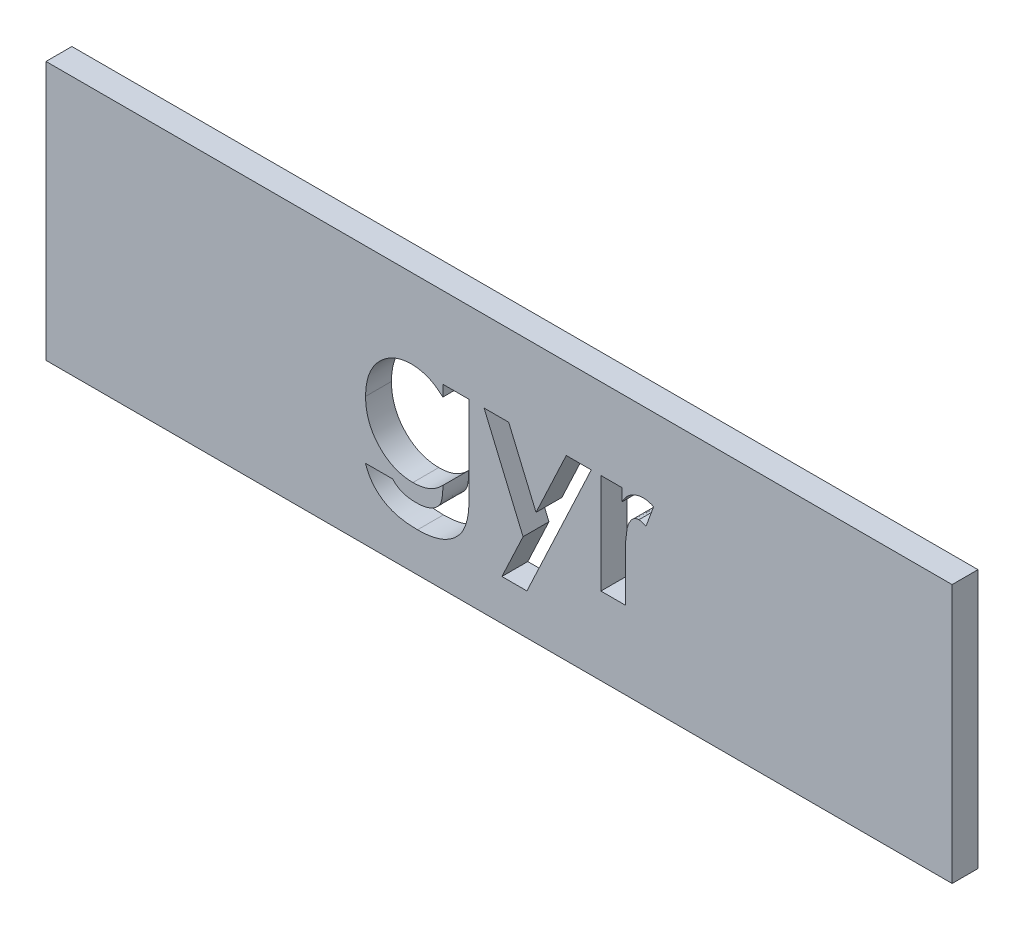
from build123d import *

# Parameters (mm, degrees)
ESQUISSE1_W             = 35
ESQUISSE1_H             = 10
BOSS_EXTRU_1_DEPTH      = 1
ESQUISSE2_R             = 1
BOSS_EXTRU_2_DEPTH      = 3
CHANFREIN1_SIZE         = 0.5
ENL_V_MAT_EXTRU_2_DEPTH = 1


with BuildPart() as part:
    # Esquisse1 → Boss.-Extru.1 (new body)
    with BuildSketch(Plane.XY):
        with Locations((17.5, -5)):
            Rectangle(ESQUISSE1_W, ESQUISSE1_H)
    extrude(amount=BOSS_EXTRU_1_DEPTH)

    # Esquisse2 → Boss.-Extru.2 (add)
    with BuildSketch(Plane(origin=(0, 0, 0), x_dir=(-1, 0, 0), z_dir=(0, 0, -1))):
        with Locations(Location((-30, -5, 0), (0, 0, 180))):  # turned: the seam where the file's is
            Circle(ESQUISSE2_R)
        with Locations(Location((-5, -5, 0), (0, 0, 180))):  # turned: the seam where the file's is
            Circle(ESQUISSE2_R)
    extrude(amount=BOSS_EXTRU_2_DEPTH)

    # Chanfrein1
    chanfrein1_edges = [part.edges().sort_by_distance(p)[0] for p in [
        (29, -5, -3),
        (4, -5, -3),
    ]]
    chamfer(chanfrein1_edges, length=CHANFREIN1_SIZE)

    # Esquisse3 → Enlèv. mat.-Extru.2 (cut)
    with BuildSketch(Plane.XY.offset(1)):
        with BuildLine():
            Line((15.329059829, -3.133012821), (16.346688034, -3.133012821))
            Line((16.346688034, -3.133012821), (16.346688034, -6.431824252))
            add(Edge.make_bspline(
                [(16.346688034, -6.431824252), (16.34546511, -6.510655339), (16.343103596, -6.662881264), (16.325089291, -6.883495949), (16.295048115, -7.088017896), (16.251819923, -7.276736757), (16.195988635, -7.4489589), (16.127704852, -7.605256879), (16.048356925, -7.746468877), (15.983115267, -7.828982437), (15.951297075, -7.869224092)],
                knots=[0, 0, 0, 0, 1.243822755, 2.401870584, 3.490053692, 4.503076575, 5.453444971, 6.342269266, 7.191528908, 8, 8, 8, 8], degree=3))
            add(Edge.make_bspline(
                [(15.951297075, -7.869224092), (15.905605713, -7.919342306), (15.814454312, -8.019324999), (15.653749283, -8.145499618), (15.477691005, -8.253338799), (15.284482771, -8.341718176), (15.074354715, -8.409035067), (14.847846635, -8.457515225), (14.604814931, -8.487710952), (14.436959436, -8.490887878), (14.350652711, -8.492521368)],
                knots=[0, 0, 0, 0, 0.916003385, 1.827369254, 2.751972866, 3.703651841, 4.69362366, 5.730423306, 6.83304546, 8, 8, 8, 8], degree=3))
            add(Edge.make_bspline(
                [(14.350652711, -8.492521368), (14.259421509, -8.491108999), (14.083960416, -8.488392649), (13.831826444, -8.461820527), (13.60215669, -8.418097933), (13.39387263, -8.356542717), (13.20503379, -8.277118686), (13.032079147, -8.181884691), (12.875340855, -8.068024611), (12.732449742, -7.940027217), (12.606719722, -7.795081621), (12.49935862, -7.6345149), (12.407892543, -7.459803946), (12.362730127, -7.334865629), (12.339776976, -7.271367521)],
                knots=[0, 0, 0, 0, 1.29412125, 2.488928388, 3.592140377, 4.607309753, 5.564519828, 6.493640275, 7.402258018, 8.307438948, 9.210158992, 10.116782752, 11.042881838, 12, 12, 12, 12], degree=3))
            Line((12.339776976, -7.271367521), (13.395566239, -7.271367521))
            add(Edge.make_bspline(
                [(13.395566239, -7.271367521), (13.419964401, -7.298227571), (13.469070776, -7.35228901), (13.555926573, -7.420889314), (13.65200877, -7.47960783), (13.758092556, -7.527688831), (13.874620253, -7.564250121), (14.000798638, -7.592026884), (14.137192891, -7.607680544), (14.231183716, -7.609591785), (14.279630743, -7.610576923)],
                knots=[0, 0, 0, 0, 0.888971165, 1.789239437, 2.70354581, 3.646217955, 4.638595249, 5.694475788, 6.811630907, 8, 8, 8, 8], degree=3))
            add(Edge.make_bspline(
                [(14.279630743, -7.610576923), (14.340855044, -7.609432982), (14.457788095, -7.607248154), (14.623222566, -7.583359441), (14.770958794, -7.5476711), (14.898864132, -7.493961019), (15.009214297, -7.42944782), (15.101273205, -7.354507352), (15.177287089, -7.271963013), (15.227008123, -7.194308957), (15.256554212, -7.123864138), (15.276673336, -7.06303605), (15.291952015, -6.992920639), (15.305859644, -6.914830211), (15.316255823, -6.827758701), (15.323143424, -6.73189057), (15.329116008, -6.627648194), (15.329078969, -6.555150823), (15.329059829, -6.517686632)],
                knots=[0, 0, 0, 0, 1.656375485, 3.163532, 4.516250129, 5.759907703, 6.905105653, 7.965920022, 8.961443813, 9.932912751, 10.442911961, 11.026787936, 11.664959534, 12.383728702, 13.174001396, 14.037595414, 14.985895623, 16, 16, 16, 16], degree=3))
            add(Edge.make_bspline(
                [(15.329059829, -6.517686632), (15.287449979, -6.55849698), (15.206252796, -6.638134021), (15.074441855, -6.739733739), (14.939510017, -6.823652606), (14.800681847, -6.89036443), (14.655196371, -6.939229664), (14.502199099, -6.974324949), (14.339947583, -6.995709064), (14.228461376, -6.99854913), (14.171507746, -7)],
                knots=[0, 0, 0, 0, 1.082007397, 2.111422008, 3.08419067, 4.02964304, 4.965866572, 5.929243163, 6.942137121, 8, 8, 8, 8], degree=3))
            add(Edge.make_bspline(
                [(14.171507746, -7), (14.108510402, -6.998544642), (13.984761279, -6.995685803), (13.802999283, -6.967903474), (13.628614811, -6.92467688), (13.461138298, -6.864501419), (13.302278657, -6.784609692), (13.149775257, -6.689560821), (13.006454432, -6.574363867), (12.870338898, -6.445449499), (12.747314548, -6.302155537), (12.639060729, -6.148258015), (12.547800043, -5.984818516), (12.473584153, -5.811988974), (12.414453061, -5.63049492), (12.373758282, -5.439353789), (12.348890609, -5.238888314), (12.345663197, -5.102267354), (12.344017094, -5.03258547)],
                knots=[0, 0, 0, 0, 1.007560175, 1.979205489, 2.935124557, 3.879618859, 4.820364716, 5.775815361, 6.749909327, 7.75781854, 8.772289371, 9.766897274, 10.764314289, 11.762244114, 12.772609037, 13.814079916, 14.885097635, 16, 16, 16, 16], degree=3))
            add(Edge.make_bspline(
                [(12.344017094, -5.03258547), (12.345454802, -4.958295142), (12.348264622, -4.813103955), (12.375808883, -4.601033686), (12.418669084, -4.399625491), (12.479853148, -4.209300672), (12.560235277, -4.030872859), (12.657373865, -3.863775883), (12.770352577, -3.706098926), (12.859784665, -3.612559125), (12.904772636, -3.565504808)],
                knots=[0, 0, 0, 0, 1.104124469, 2.157873671, 3.173961494, 4.162551312, 5.124378318, 6.07778831, 7.033049473, 8, 8, 8, 8], degree=3))
            add(Edge.make_bspline(
                [(12.904772636, -3.565504808), (12.947465572, -3.525382692), (13.031594135, -3.446320058), (13.169312331, -3.344869576), (13.311943127, -3.257855372), (13.461442861, -3.187862255), (13.616753673, -3.132123568), (13.778795018, -3.093129933), (13.946761183, -3.069087357), (14.06083064, -3.066486156), (14.118506277, -3.06517094)],
                knots=[0, 0, 0, 0, 1.042068658, 2.053448347, 3.038272799, 4.011764631, 4.986555969, 5.970496305, 6.973845226, 8, 8, 8, 8], degree=3))
            add(Edge.make_bspline(
                [(14.118506277, -3.06517094), (14.172628334, -3.066690669), (14.279874619, -3.069702107), (14.438767019, -3.090949078), (14.592626627, -3.128484935), (14.743138098, -3.180088848), (14.891896731, -3.24693584), (15.038773976, -3.334551701), (15.186747723, -3.439315509), (15.280642236, -3.521173765), (15.329059829, -3.563384749)],
                knots=[0, 0, 0, 0, 0.968122651, 1.918396369, 2.861262201, 3.796768263, 4.761417965, 5.77287463, 6.85156174, 8, 8, 8, 8], degree=3))
            Line((15.329059829, -3.563384749), (15.329059829, -3.133012821))
        make_face()
        Polygon((16.921223958, -3.133012821), (17.872070313, -3.133012821), (18.927859575, -5.620901776), (20.096011952, -3.133012821), (21.061698718, -3.133012821), (18.575929821, -8.424679487), (17.610243056, -8.424679487), (18.427525708, -6.685171274), align=None)
        with BuildLine():
            Line((21.43482906, -3.133012821), (22.248931624, -3.133012821))
            Line((22.248931624, -3.133012821), (22.248931624, -3.608966012))
            add(Edge.make_bspline(
                [(22.248931624, -3.608966012), (22.271961023, -3.566667921), (22.316972938, -3.483994547), (22.399663601, -3.373021915), (22.494661984, -3.27956386), (22.598554501, -3.201665623), (22.71165603, -3.140951595), (22.830937914, -3.097685197), (22.955379698, -3.069568033), (23.040269665, -3.066647192), (23.083174746, -3.06517094)],
                knots=[0, 0, 0, 0, 1.09866127, 2.147379032, 3.14564304, 4.131443017, 5.102343063, 6.064490016, 7.021754664, 8, 8, 8, 8], degree=3))
            add(Edge.make_bspline(
                [(23.083174746, -3.06517094), (23.114329189, -3.066629785), (23.177770759, -3.069600514), (23.27446464, -3.086869409), (23.372553644, -3.118094854), (23.43710466, -3.146209218), (23.47008547, -3.160573584)],
                knots=[0, 0, 0, 0, 0.931404136, 1.896671404, 2.925354185, 4, 4, 4, 4], degree=3))
            Line((23.47008547, -3.160573584), (23.175397302, -3.965135884))
            add(Edge.make_bspline(
                [(23.175397302, -3.965135884), (23.149056388, -3.952409228), (23.09954561, -3.928488014), (23.027664556, -3.900258516), (22.96242952, -3.883034257), (22.921071704, -3.880464246), (22.901909722, -3.879273504)],
                knots=[0, 0, 0, 0, 1.214386998, 2.282580073, 3.20428172, 4, 4, 4, 4], degree=3))
            add(Edge.make_bspline(
                [(22.901909722, -3.879273504), (22.883817085, -3.880062553), (22.848225749, -3.881614748), (22.795693934, -3.894916529), (22.746219903, -3.917855038), (22.697419506, -3.947241545), (22.653142553, -3.988090988), (22.608892949, -4.03538147), (22.569897828, -4.093767862), (22.528746666, -4.15875488), (22.493707924, -4.238298932), (22.463663281, -4.333258138), (22.436893263, -4.444731242), (22.418471836, -4.57331011), (22.400666787, -4.717750521), (22.390068784, -4.879112649), (22.382169959, -5.056886251), (22.381686999, -5.180978642), (22.381435296, -5.245651376)],
                knots=[0, 0, 0, 0, 0.544232178, 1.070598461, 1.618251235, 2.182094276, 2.777567932, 3.425210017, 4.127676488, 4.886675562, 5.738955394, 6.734782583, 7.883056018, 9.186093582, 10.642914445, 12.264202625, 14.053029461, 16, 16, 16, 16], degree=3))
            Line((22.381435296, -5.245651376), (22.384615385, -5.434336605))
            Line((22.384615385, -5.434336605), (22.384615385, -7))
            Line((22.384615385, -7), (21.43482906, -7))
            Line((21.43482906, -7), (21.43482906, -3.133012821))
        make_face()
    extrude(amount=-ENL_V_MAT_EXTRU_2_DEPTH, mode=Mode.SUBTRACT)


solid = part.part
